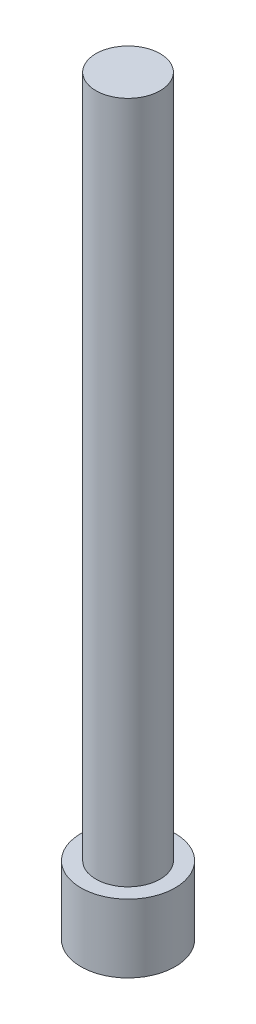
from build123d import *

# Parameters (mm, degrees)
SKETCH1_R           = 2.35
BOSS_EXTRUDE1_DEPTH = 55
SKETCH2_R           = 3.45
SKETCH2_R_2         = 2.35
BOSS_EXTRUDE2_DEPTH = 5


with BuildPart() as part:
    # Sketch1 → Boss-Extrude1 (new body)
    with BuildSketch(Plane(origin=(0, 0, 0), x_dir=(1, 0, 0), z_dir=(0, 1, 0))):
        with Locations(Location((0, 0, 0), (0, 0, 270))):  # turned: the seam where the file's is
            Circle(SKETCH1_R)
    extrude(amount=BOSS_EXTRUDE1_DEPTH)

    # Sketch2 → Boss-Extrude2 (add)
    with BuildSketch(Plane.XZ):
        with Locations(Location((0, 0, 0), (0, 0, 270))):  # turned: the seam where the file's is
            Circle(SKETCH2_R)
        with Locations(Location((0, 0, 0), (0, 0, 270))):  # turned: the seam where the file's is
            Circle(SKETCH2_R_2, mode=Mode.SUBTRACT)
    extrude(amount=-BOSS_EXTRUDE2_DEPTH)


solid = part.part
